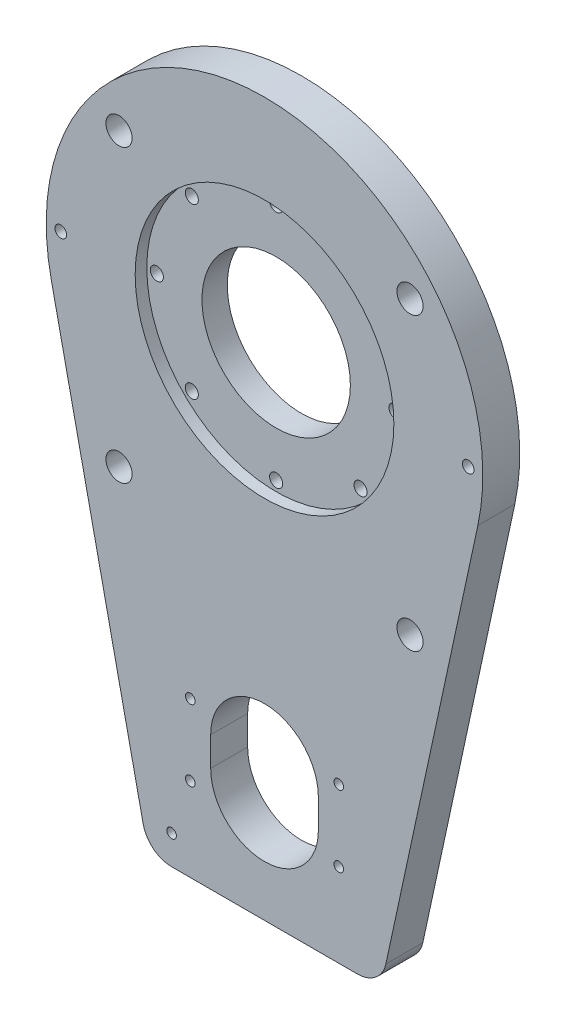
from build123d import *

# Parameters (mm, degrees)
BOSS_EXTRUDE1_DEPTH                                 = 12.7
CUT_EXTRUDE1_DEPTH                                  = 13.7
HOLE1_D                                             = 9
HOLE1_DEPTH                                         = 12.7
F_4_CLEARANCE_HOLE1_D                               = 3.3
F_4_CLEARANCE_HOLE1_DEPTH                           = 12.7
HOLE2_D                                             = 51
HOLE2_DEPTH                                         = 12.7
HOLE2_CBORE_D                                       = 88.9
HOLE2_CBORE_DEPTH                                   = 4
CBORE_FOR_8_BINDING_HEAD_MACHINE_SCREW1_D           = 4.5
CBORE_FOR_8_BINDING_HEAD_MACHINE_SCREW1_DEPTH       = 12.7
CBORE_FOR_8_BINDING_HEAD_MACHINE_SCREW1_CBORE_D     = 8.25
CBORE_FOR_8_BINDING_HEAD_MACHINE_SCREW1_CBORE_DEPTH = 4
FILLET1_R                                           = 10
SKETCH11_R                                          = 2
CUT_EXTRUDE2_DEPTH                                  = 13.7


with BuildPart() as part:
    # Sketch1 → Boss-Extrude1 (new body)
    with BuildSketch(Plane.XY.offset(12.7)):
        with BuildLine():
            Line((40, -170), (73.308387301, -15.839202988))
            ThreePointArc((73.308387301, -15.839202988), (0, 75), (-73.308387301, -15.839202988))
            Line((-73.308387301, -15.839202988), (-40, -170))
            Line((-40, -170), (40, -170))
        make_face()
    extrude(amount=-BOSS_EXTRUDE1_DEPTH)

    # Sketch2 → Cut-Extrude1 (cut, through all)
    with BuildSketch(Plane(origin=(0, 0, 0), x_dir=(-1, 0, 0), z_dir=(0, 0, -1))):
        with BuildLine():
            Line((-18.5, -124), (-18.5, -134))
            ThreePointArc((-18.5, -134), (0, -152.5), (18.5, -134))
            Line((18.5, -134), (18.5, -124))
            ThreePointArc((18.5, -124), (0, -105.5), (-18.5, -124))
        make_face()
    extrude(amount=-CUT_EXTRUDE1_DEPTH, mode=Mode.SUBTRACT)

    # Hole1
    with Locations(Plane(origin=(0, 0, 0), x_dir=(-1, 0, 0), z_dir=(0, 0, -1))):
        with Locations((-50, -60), (50, -60), (50, 40), (-50, 40)):
            Hole(HOLE1_D / 2, depth=HOLE1_DEPTH)

    # #4 Clearance Hole1
    with Locations(Plane.XY.offset(12.7)):
        with Locations((-31.929873349, -160), (-25.5, -116.75), (-25.5, -141.25), (25.5, -116.75), (25.5, -141.25)):
            Hole(F_4_CLEARANCE_HOLE1_D / 2, depth=F_4_CLEARANCE_HOLE1_DEPTH)

    # Hole2
    with Locations(Plane.XY.offset(12.7)):
        with Locations((0, 0)):
            CounterBoreHole(HOLE2_D / 2, HOLE2_CBORE_D / 2, HOLE2_CBORE_DEPTH, depth=HOLE2_DEPTH)

    # CBORE for #8 Binding Head Machine Screw1
    with Locations(Plane(origin=(0, 0, 0), x_dir=(-1, 0, 0), z_dir=(0, 0, -1))):
        with Locations((28.991378029, 28.991378029), (41, 0), (28.991378029, -28.991378029), (0, -41), (-28.991378029, -28.991378029), (-41, 0), (-28.991378029, 28.991378029), (0, 41)):
            CounterBoreHole(CBORE_FOR_8_BINDING_HEAD_MACHINE_SCREW1_D / 2, CBORE_FOR_8_BINDING_HEAD_MACHINE_SCREW1_CBORE_D / 2, CBORE_FOR_8_BINDING_HEAD_MACHINE_SCREW1_CBORE_DEPTH, depth=CBORE_FOR_8_BINDING_HEAD_MACHINE_SCREW1_DEPTH)

    # Fillet1
    fillet1_edges = [part.edges().sort_by_distance(p)[0] for p in [
        (-40, -170, 6.35),
        (40, -170, 6.35),
    ]]
    fillet(fillet1_edges, radius=FILLET1_R)

    # Sketch11 → Cut-Extrude2 (cut, through all)
    with BuildSketch(Plane.XY.offset(12.7)):
        with Locations((-70, 0)):
            Circle(SKETCH11_R)
        with Locations((70, 0)):
            Circle(SKETCH11_R)
    extrude(amount=-CUT_EXTRUDE2_DEPTH, mode=Mode.SUBTRACT)


solid = part.part
